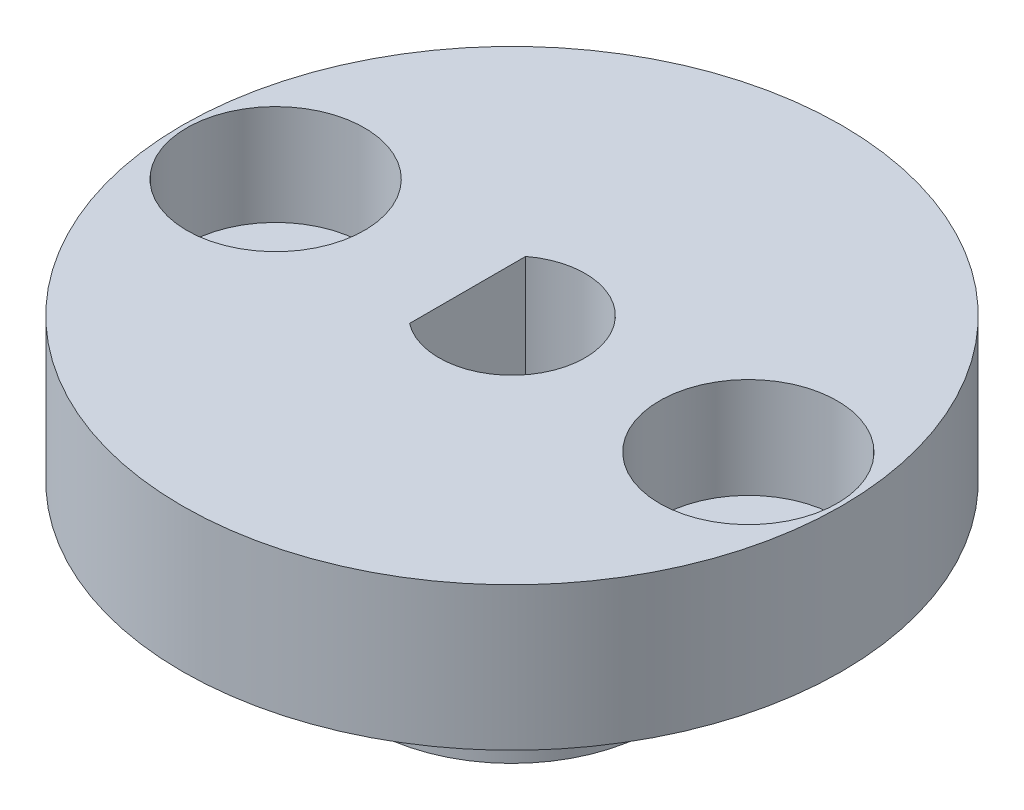
from build123d import *

# Parameters (mm, degrees)
CROQUIS1_R              = 11.5
SALIENTE_EXTRUIR1_DEPTH = 5
CROQUIS2_R              = 4.99
SALIENTE_EXTRUIR2_DEPTH = 5
CROQUIS3_R              = 1.6
CORTAR_EXTRUIR1_DEPTH   = 6
CORTAR_EXTRUIR2_DEPTH   = 11
CROQUIS5_R              = 3.1
CORTAR_EXTRUIR3_DEPTH   = 3.5


with BuildPart() as part:
    # Croquis1 → Saliente-Extruir1 (new body)
    with BuildSketch(Plane(origin=(0, 0, 0), x_dir=(1, 0, 0), z_dir=(0, 1, 0))):
        Circle(CROQUIS1_R)
    extrude(amount=SALIENTE_EXTRUIR1_DEPTH)

    # Croquis2 → Saliente-Extruir2 (add)
    with BuildSketch(Plane.XZ):
        Circle(CROQUIS2_R)
    extrude(amount=SALIENTE_EXTRUIR2_DEPTH)

    # Croquis3 → Cortar-Extruir1 (cut, through all)
    with BuildSketch(Plane.XZ):
        with Locations((-8.245, 0)):
            Circle(CROQUIS3_R)
        with Locations((8.245, 0)):
            Circle(CROQUIS3_R)
    extrude(amount=-CORTAR_EXTRUIR1_DEPTH, mode=Mode.SUBTRACT)

    # Croquis4 → Cortar-Extruir2 (cut, through all)
    with BuildSketch(Plane.XZ.offset(5)):
        with BuildLine():
            Line((-1.55, 2.024845673), (-1.55, -2.024845673))
            ThreePointArc((-1.55, -2.024845673), (2.55, 0), (-1.55, 2.024845673))
        make_face()
    extrude(amount=-CORTAR_EXTRUIR2_DEPTH, mode=Mode.SUBTRACT)

    # Croquis5 → Cortar-Extruir3 (cut)
    with BuildSketch(Plane(origin=(0, 5, 0), x_dir=(1, 0, 0), z_dir=(0, 1, 0))):
        with Locations((-8.245, 0)):
            Circle(CROQUIS5_R)
        with Locations((8.245, 0)):
            Circle(CROQUIS5_R)
    extrude(amount=-CORTAR_EXTRUIR3_DEPTH, mode=Mode.SUBTRACT)


solid = part.part
